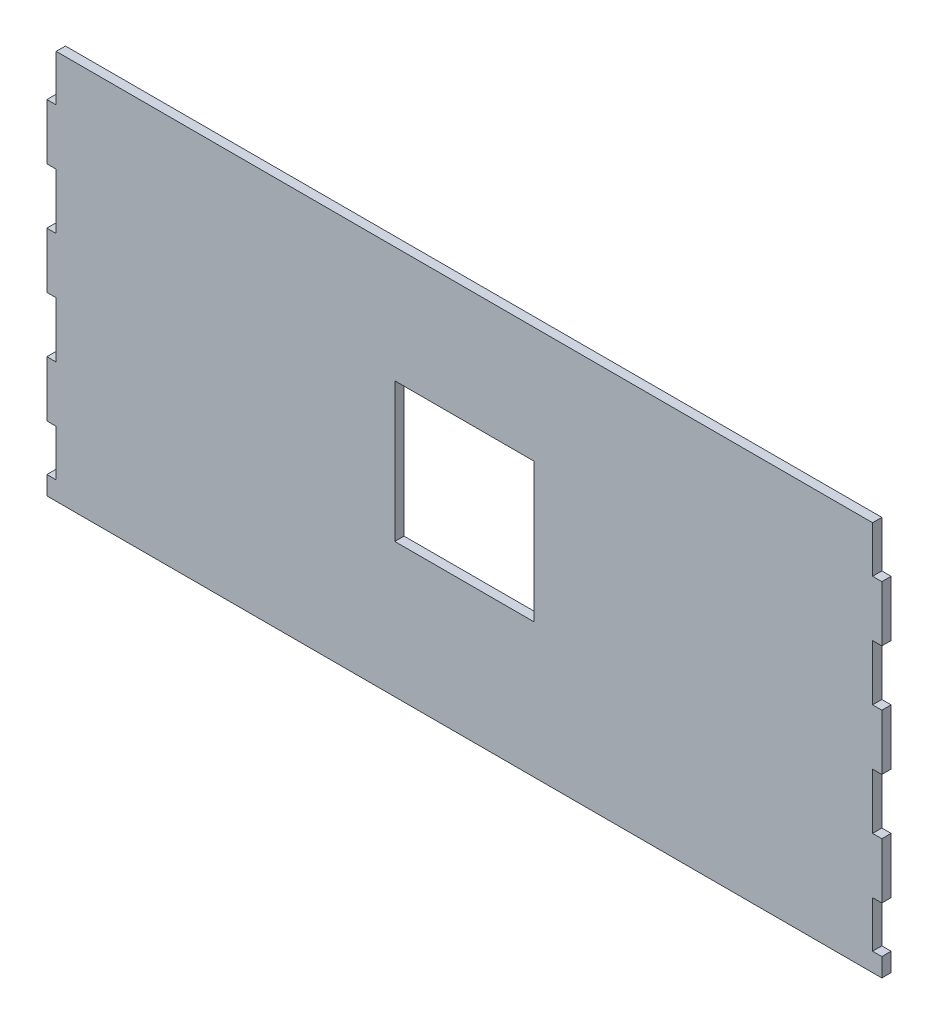
from build123d import *

# Parameters (mm, degrees)
SKETCH1_W           = 450
SKETCH1_H           = 210
BOSS_EXTRUDE1_DEPTH = 5
SKETCH3_W           = 65.821391225
SKETCH3_H           = 25
SKETCH3_W_2         = 143.228691138
SKETCH3_H_2         = 30
SKETCH3_W_3         = 192.205874683
SKETCH3_W_4         = 194.707934706
SKETCH3_W_5         = 70.821391225
SKETCH3_W_6         = 148.228691138
SKETCH3_W_7         = 194.705874683
SKETCH3_W_8         = 199.707934706
CUT_EXTRUDE1_DEPTH  = 6
SKETCH4_W           = 75
SKETCH4_H           = 75
CUT_EXTRUDE2_DEPTH  = 6


with BuildPart() as part:
    # Sketch1 → Boss-Extrude1 (new body)
    with BuildSketch(Plane.XY):
        Rectangle(SKETCH1_W, SKETCH1_H)
    extrude(amount=BOSS_EXTRUDE1_DEPTH)

    # Sketch3 → Cut-Extrude1 (cut, through all)
    with BuildSketch(Plane(origin=(0, 0, 0), x_dir=(-1, 0, 0), z_dir=(0, 0, -1))):
        with Locations((-252.910695613, 92.5)):
            Rectangle(SKETCH3_W, SKETCH3_H)
        with Locations((-291.614345569, 35)):
            Rectangle(SKETCH3_W_2, SKETCH3_H_2)
        with Locations((-316.102937342, -25)):
            Rectangle(SKETCH3_W_3, SKETCH3_H_2)
        with Locations((-317.353967353, -82.5)):
            Rectangle(SKETCH3_W_4, SKETCH3_H)
        with Locations((255.410695613, 92.5)):
            Rectangle(SKETCH3_W_5, SKETCH3_H)
        with Locations((294.114345569, 35)):
            Rectangle(SKETCH3_W_6, SKETCH3_H_2)
        with Locations((317.352937342, -25)):
            Rectangle(SKETCH3_W_7, SKETCH3_H_2)
        with Locations((319.853967353, -82.5)):
            Rectangle(SKETCH3_W_8, SKETCH3_H)
    extrude(amount=-CUT_EXTRUDE1_DEPTH, mode=Mode.SUBTRACT)

    # Sketch4 → Cut-Extrude2 (cut, through all)
    with BuildSketch(Plane(origin=(0, 0, 0), x_dir=(-1, 0, 0), z_dir=(0, 0, -1))):
        with Locations((0, 5)):
            Rectangle(SKETCH4_W, SKETCH4_H)
    extrude(amount=-CUT_EXTRUDE2_DEPTH, mode=Mode.SUBTRACT)


solid = part.part
